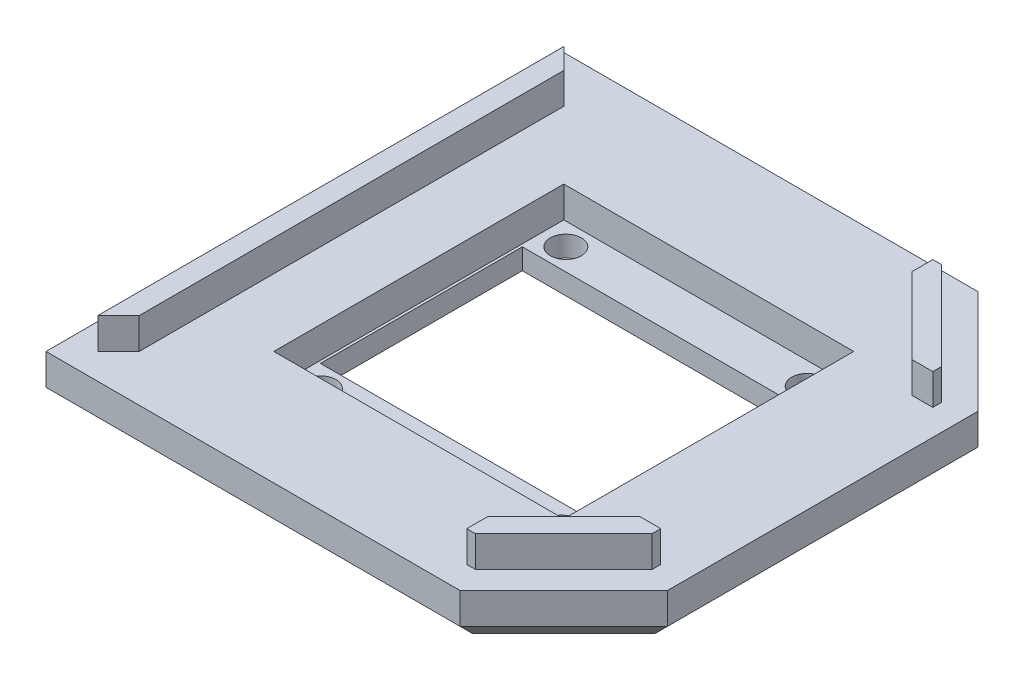
from build123d import *

# Parameters (mm, degrees)
BOSS_EXTRUDE1_DEPTH = 5
BOSS_EXTRUDE2_DEPTH = 3
CHAMFER1_SIZE       = 2
SKETCH4_R           = 1.5
SKETCH4_W           = 27.5
SKETCH4_H           = 19.5
CUT_EXTRUDE2_DEPTH  = 8
SKETCH5_W           = 28
SKETCH5_H           = 28
CUT_EXTRUDE3_DEPTH  = 3


with BuildPart() as part:
    # Sketch1 → Boss-Extrude1 (new body)
    with BuildSketch(Plane(origin=(0, 0, 0), x_dir=(1, 0, 0), z_dir=(0, 1, 0))):
        Polygon((15, 25), (25, 15), (25, -15), (15, -25), (-25, -25), (-25, 25), align=None)
    extrude(amount=BOSS_EXTRUDE1_DEPTH)

    # Sketch2 → Boss-Extrude2 (add)
    with BuildSketch(Plane(origin=(0, 5, 0), x_dir=(1, 0, 0), z_dir=(0, 1, 0))):
        Polygon((-20.5, 20.5), (-20.5, -20.5), (-22.5, -22.5), (-22.5, 22.5), align=None)
        Polygon((13.964466094, 22.5), (13.136038969, 22.5), (13.136038969, 20.5), (20.5, 13.136038969), (22.5, 13.136038969), (22.5, 13.964466094), align=None)
        Polygon((13.136038969, -20.5), (13.136038969, -22.5), (13.964466094, -22.5), (22.5, -13.964466094), (22.5, -13.136038969), (20.5, -13.136038969), align=None)
    extrude(amount=BOSS_EXTRUDE2_DEPTH)

    # Chamfer1
    chamfer1_edges = [part.edges().sort_by_distance(p)[0] for p in [
        (-5, 0, -25),
        (20, 0, -20),
        (25, 0, 0),
        (20, 0, 20),
        (-5, 0, 25),
        (-25, 0, 0),
    ]]
    chamfer(chamfer1_edges, length=CHAMFER1_SIZE)

    # Sketch4 → Cut-Extrude2 (cut)
    with BuildSketch(Plane(origin=(0, 0, 0), x_dir=(-1, 0, 0), z_dir=(0, -1, 0))):
        with Locations((-11.65, -11.85)):
            Circle(SKETCH4_R)
        with Locations((11.65, -11.85)):
            Circle(SKETCH4_R)
        with Locations((11.65, 11.85)):
            Circle(SKETCH4_R)
        with Locations((-11.65, 11.85)):
            Circle(SKETCH4_R)
        Rectangle(SKETCH4_W, SKETCH4_H)
    extrude(amount=-CUT_EXTRUDE2_DEPTH, mode=Mode.SUBTRACT)

    # Sketch5 → Cut-Extrude3 (cut)
    with BuildSketch(Plane(origin=(0, 5, 0), x_dir=(1, 0, 0), z_dir=(0, 1, 0))):
        Rectangle(SKETCH5_W, SKETCH5_H)
    extrude(amount=-CUT_EXTRUDE3_DEPTH, mode=Mode.SUBTRACT)


solid = part.part
